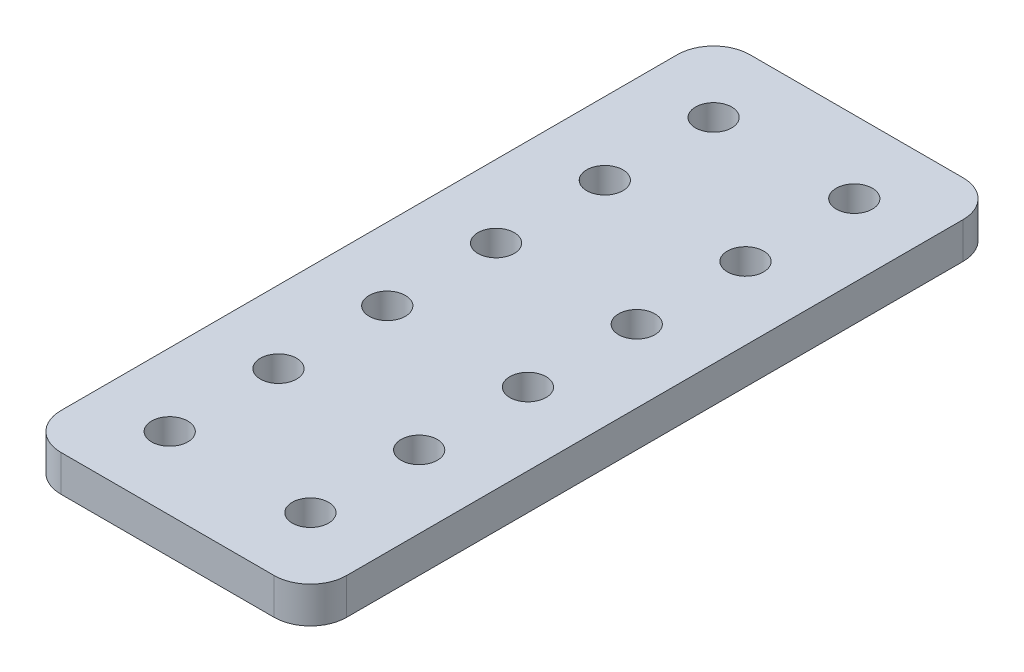
from build123d import *

# Parameters (mm, degrees)
SKETCH1_W           = 50.038
SKETCH1_H           = 120.65
SKETCH1_R           = 3.175
BOSS_EXTRUDE1_DEPTH = 6.35
FILLET1_R           = 6.35


with BuildPart() as part:
    # Sketch1 → Boss-Extrude1 (new body)
    with BuildSketch(Plane(origin=(0, 0, 0), x_dir=(1, 0, 0), z_dir=(0, 1, 0))):
        Rectangle(SKETCH1_W, SKETCH1_H)
        with Locations((12.319, -47.625)):
            Circle(SKETCH1_R, mode=Mode.SUBTRACT)
        with Locations((-12.319, -47.625)):
            Circle(SKETCH1_R, mode=Mode.SUBTRACT)
        with Locations((12.319, -28.575)):
            Circle(SKETCH1_R, mode=Mode.SUBTRACT)
        with Locations((-12.319, -28.575)):
            Circle(SKETCH1_R, mode=Mode.SUBTRACT)
        with Locations((12.319, -9.525)):
            Circle(SKETCH1_R, mode=Mode.SUBTRACT)
        with Locations((-12.319, -9.525)):
            Circle(SKETCH1_R, mode=Mode.SUBTRACT)
        with Locations((12.319, 9.525)):
            Circle(SKETCH1_R, mode=Mode.SUBTRACT)
        with Locations((-12.319, 9.525)):
            Circle(SKETCH1_R, mode=Mode.SUBTRACT)
        with Locations((12.319, 28.575)):
            Circle(SKETCH1_R, mode=Mode.SUBTRACT)
        with Locations((-12.319, 28.575)):
            Circle(SKETCH1_R, mode=Mode.SUBTRACT)
        with Locations((12.319, 47.625)):
            Circle(SKETCH1_R, mode=Mode.SUBTRACT)
        with Locations((-12.319, 47.625)):
            Circle(SKETCH1_R, mode=Mode.SUBTRACT)
    extrude(amount=BOSS_EXTRUDE1_DEPTH)

    # Fillet1
    fillet1_edges = [part.edges().sort_by_distance(p)[0] for p in [
        (25.019, 3.175, 60.325),
        (-25.019, 3.175, 60.325),
        (-25.019, 3.175, -60.325),
        (25.019, 3.175, -60.325),
    ]]
    fillet(fillet1_edges, radius=FILLET1_R)


solid = part.part
